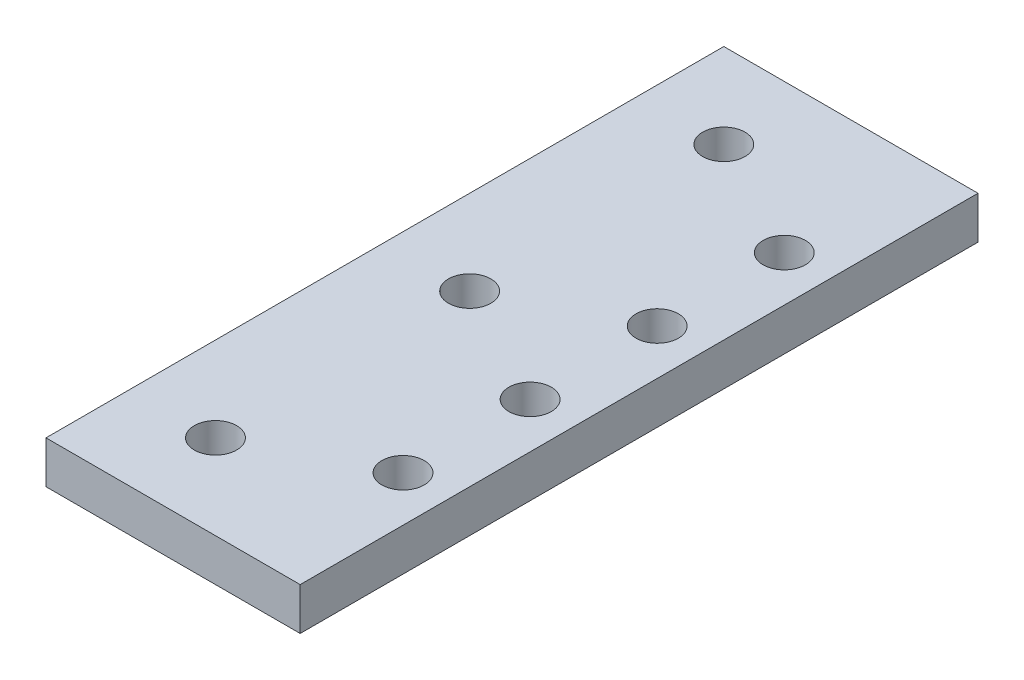
from build123d import *

# Parameters (mm, degrees)
SKETCH2_W           = 38.1
SKETCH2_H           = 101.6
SKETCH2_R           = 3.175
BOSS_EXTRUDE1_DEPTH = 6.35
SKETCH3_R           = 3.175
CUT_EXTRUDE2_DEPTH  = 7.35


with BuildPart() as part:
    # Sketch2 → Boss-Extrude1 (new body)
    with BuildSketch(Plane(origin=(0, 0, 0), x_dir=(1, 0, 0), z_dir=(0, 1, 0))):
        with Locations((6.35, 0)):
            Rectangle(SKETCH2_W, SKETCH2_H)
        Circle(SKETCH2_R, mode=Mode.SUBTRACT)
        with Locations((0, 38.1)):
            Circle(SKETCH2_R, mode=Mode.SUBTRACT)
        with Locations((0, -38.1)):
            Circle(SKETCH2_R, mode=Mode.SUBTRACT)
    extrude(amount=BOSS_EXTRUDE1_DEPTH)

    # Sketch3 → Cut-Extrude2 (cut, through all)
    with BuildSketch(Plane(origin=(0, 6.35, 0), x_dir=(1, 0, 0), z_dir=(0, 1, 0))):
        with Locations((18.58962745, 28.575)):
            Circle(SKETCH3_R)
        with Locations((18.58962745, 9.525)):
            Circle(SKETCH3_R)
        with Locations((18.58962745, -9.525)):
            Circle(SKETCH3_R)
        with Locations((18.58962745, -28.575)):
            Circle(SKETCH3_R)
    extrude(amount=-CUT_EXTRUDE2_DEPTH, mode=Mode.SUBTRACT)


solid = part.part
